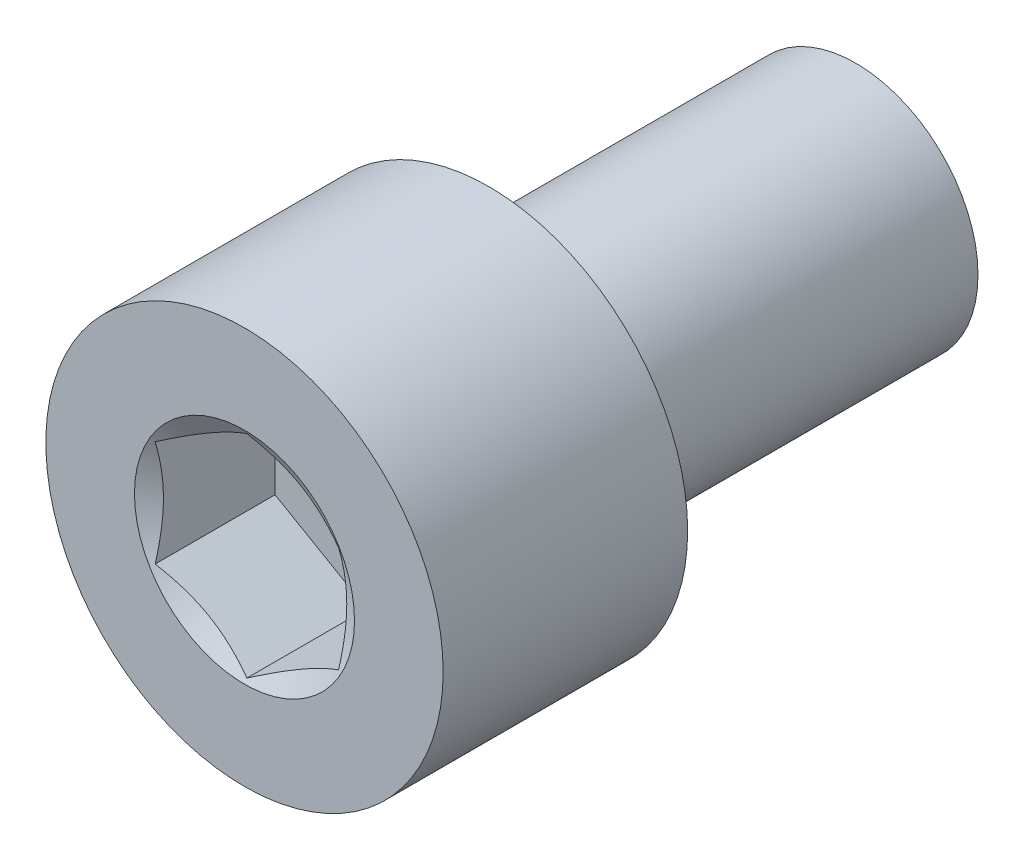
from build123d import *

# Parameters (mm, degrees)
SKE1_R      = 6.5
BASE1_DEPTH = 8
BODYSKE_W   = 20
BODYSKE_H   = 4
HEX_2_DEPTH = 4


with BuildPart() as part:
    # Ske1 → Base1 (new body)
    with BuildSketch(Plane.XY):
        Circle(SKE1_R)
    extrude(amount=BASE1_DEPTH)

    # BodySke → BaseBody (revolve)
    with BuildSketch(Plane(origin=(0, 0, 0), x_dir=(0, 0, -1), z_dir=(1, 0, 0)), mode=Mode.PRIVATE) as basebody_sk:
        with Locations((2, 2)):
            Rectangle(BODYSKE_W, BODYSKE_H)
    revolve(basebody_sk.sketch.rotate(Axis((0, 0, 1.385793675), (0, 0, -1)), 90), axis=Axis((0, 0, 1.385793675), (0, 0, -1)))

    # Ske8 → Hex 2 (cut)
    with BuildSketch(Plane.XY.offset(8)):
        Polygon((0, 3.464101615), (-3, 1.732050808), (-3, -1.732050808), (0, -3.464101615), (3, -1.732050808), (3, 1.732050808), align=None)
    extrude(amount=-HEX_2_DEPTH, mode=Mode.SUBTRACT)

    # Chamfer 2 cone 1 section (through the dimple's axis) → Chamfer 2 (revolve, cut)
    with BuildSketch(Plane(origin=(0, 0, 8), x_dir=(0, -1, 0), z_dir=(1, 0, 0))):
        Polygon((0, 0), (3.6, 0), (0, 2.078460969), align=None)
    revolve(axis=Axis((0, 0, 8), (0, 0, -1)), mode=Mode.SUBTRACT)


solid = part.part
